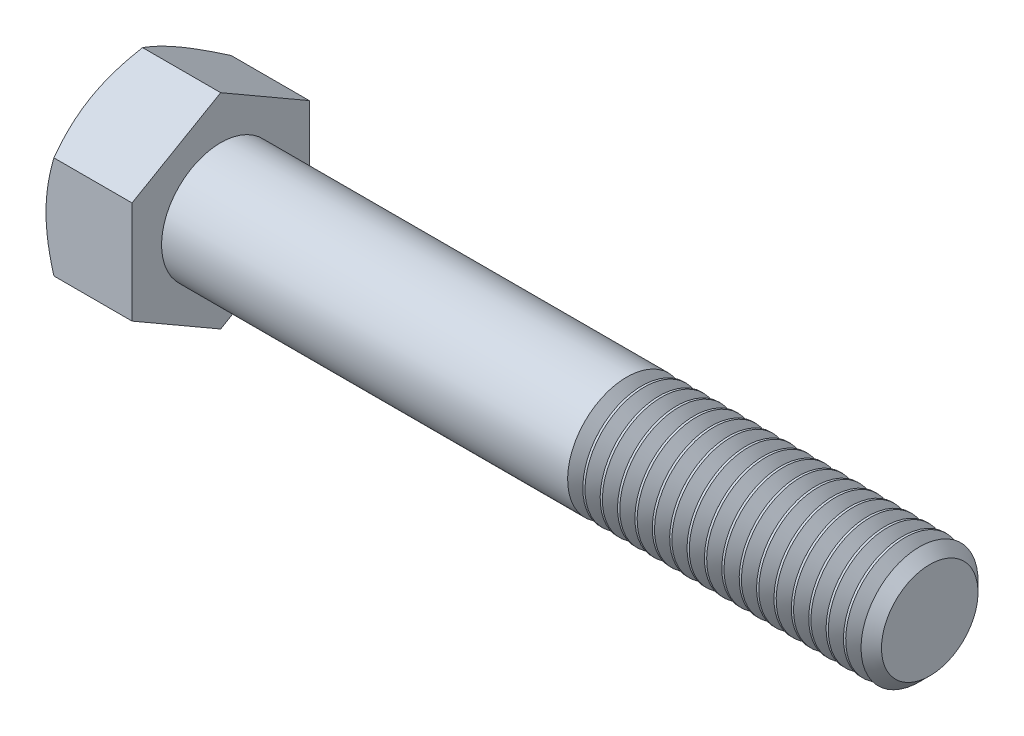
from build123d import *

# Parameters (mm, degrees)
BASEHEAD_DEPTH  = 9.2456
THDSCHPAT_COUNT = 17
THDSCHPAT_PITCH = 1.867647059


with BuildPart() as part:
    # Sketch1 → BaseHead (new body)
    with BuildSketch(Plane(origin=(0, 0, 0), x_dir=(0, 0, -1), z_dir=(1, 0, 0))):
        Polygon((9.525, 5.499261314), (9.525, -5.499261314), (0, -10.998522628), (-9.525, -5.499261314), (-9.525, 5.499261314), (0, 10.998522628), align=None)
    extrude(amount=BASEHEAD_DEPTH)

    # BodySke → BaseBody (revolve)
    with BuildSketch(Plane.XY):
        Polygon((0, 0), (85.4456, 0), (85.4456, 5.18668), (84.28228, 6.35), (0, 6.35), align=None)
    revolve(axis=Axis((0, 0, 0), (1, 0, 0)))

    # Sketch3 → HeadChamfer (revolve, cut)
    with BuildSketch(Plane.XY):
        Polygon((0, 9.525), (4.516912895, 17.348522628), (4.516912895, 23.698522628), (-12.7, 23.698522628), (-12.7, 9.525), align=None)
    revolve(axis=Axis((0, 0, 0), (1, 0, 0)), mode=Mode.SUBTRACT)

    # ThdSchSke → ThreadSchematic (revolve, cut)
    with BuildSketch(Plane.XY):
        Polygon((53.6956, -5.18668), (52.881034567, -6.35), (52.881034567, -7.9375), (54.510165433, -7.9375), (54.510165433, -6.35), align=None)
    threadschematic = revolve(axis=Axis((-3.175, 0, 0), (1, 0, 0)), mode=Mode.SUBTRACT)

    # ThdSchPat: ThreadSchematic ×17
    with Locations(*[(i * THDSCHPAT_PITCH, 0, 0) for i in range(1, THDSCHPAT_COUNT)]):
        add(threadschematic, mode=Mode.SUBTRACT)


solid = part.part
